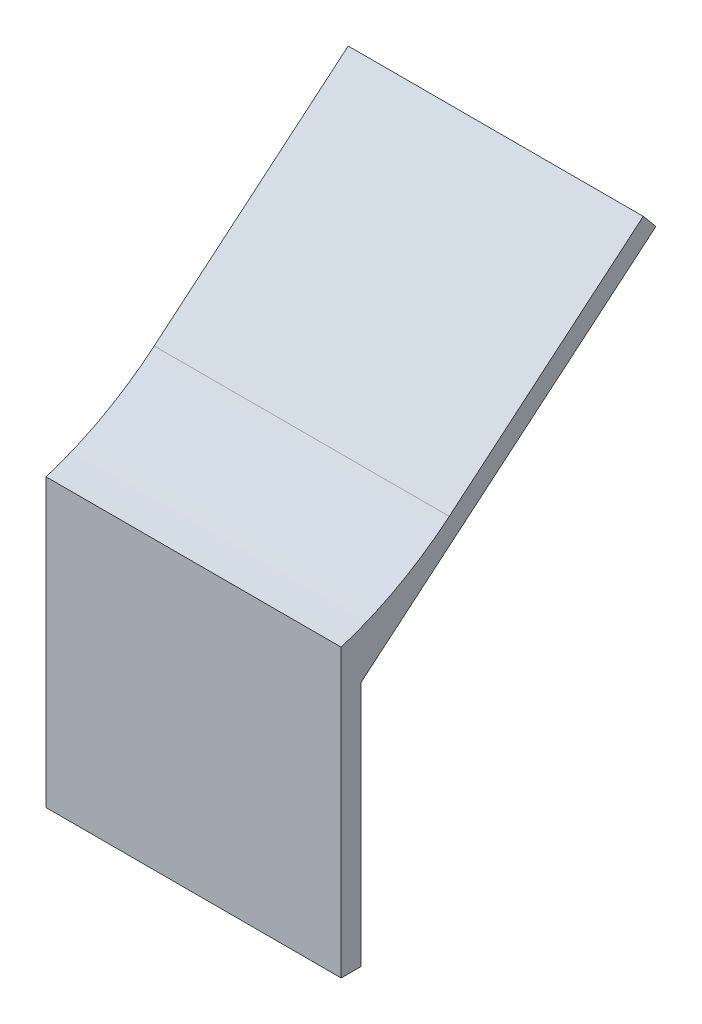
from build123d import *

# Parameters (mm, degrees)
BOSS_EXTRUDE1_DEPTH = 30


with BuildPart() as part:
    # Sketch1 → Boss-Extrude1 (new body)
    with BuildSketch(Plane(origin=(0, 0, 0), x_dir=(0, 0, -1), z_dir=(1, 0, 0))):
        with BuildLine():
            Line((0, 0), (0, 29.130560593))
            ThreePointArc((0, 29.130560593), (5.792341896, 31.60023967), (10.990207869, 35.154494686))
            Line((10.990207869, 35.154494686), (30.714424781, 51.705077822))
            Line((30.714424781, 51.705077822), (32, 50.172988935))
            Line((32, 50.172988935), (2, 25))
            Line((2, 25), (2, 0))
            Line((2, 0), (0, 0))
        make_face()
    extrude(amount=BOSS_EXTRUDE1_DEPTH)


solid = part.part
